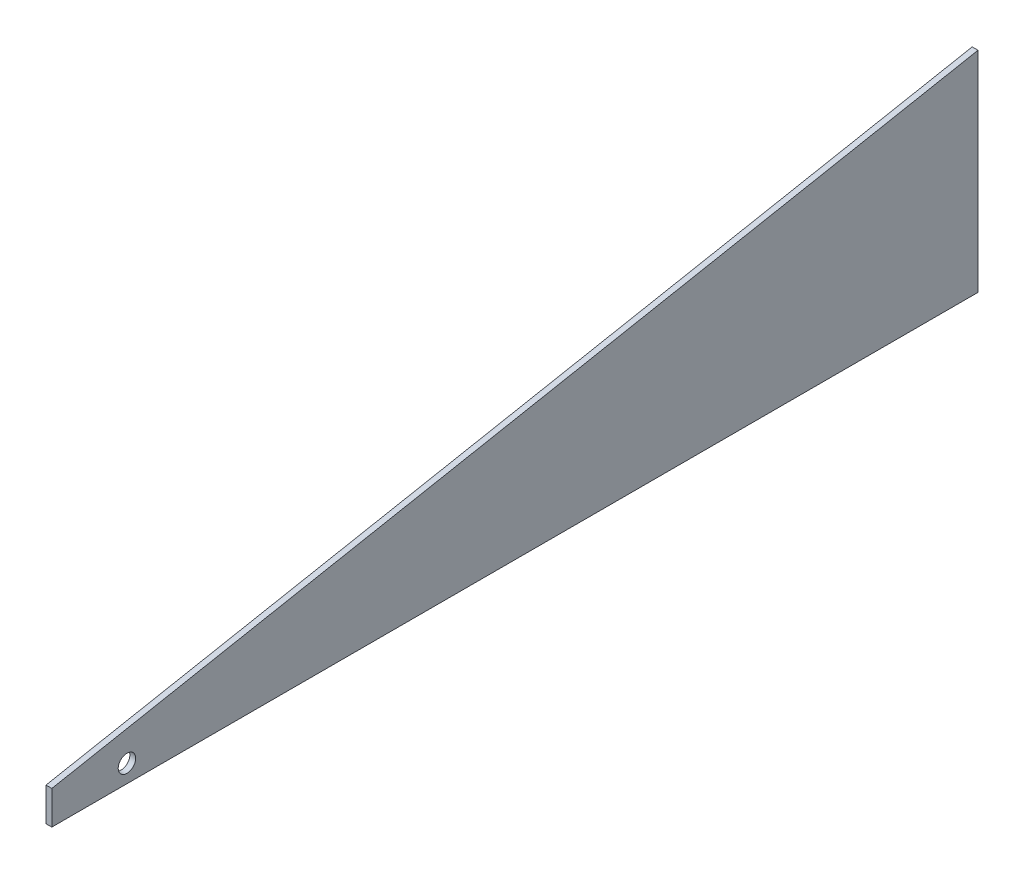
from build123d import *

# Parameters (mm, degrees)
RESSALTO_EXTRUS_O1_DEPTH                       = 2
BROCA_DE_ROSQUEAR_DE_CANO_PARA_TARRAXA_D_D     = 6
BROCA_DE_ROSQUEAR_DE_CANO_PARA_TARRAXA_D_DEPTH = 4
BROCA_DE_ROSQUEAR_DE_CANO_PARA_TARRAXA_D_TIP   = 1.802581857


with BuildPart() as part:
    # Esboço1 → Ressalto-extrusão1 (new body)
    with BuildSketch(Plane(origin=(0, 0, 0), x_dir=(0, 0, -1), z_dir=(1, 0, 0))):
        Polygon((-131, -26), (-131, -37.5), (187, -37.5), (187, 34.5), align=None)
    extrude(amount=RESSALTO_EXTRUS_O1_DEPTH)

    # Broca de rosquear de cano para tarraxa de 1/810
    with Locations(Plane(origin=(2, 0, 0), x_dir=(0, 0, -1), z_dir=(1, 0, 0))):
        with Locations((-105.202549234, -31.420254628)):
            Hole(BROCA_DE_ROSQUEAR_DE_CANO_PARA_TARRAXA_D_D / 2, depth=BROCA_DE_ROSQUEAR_DE_CANO_PARA_TARRAXA_D_DEPTH)
            with Locations((0, 0, -(BROCA_DE_ROSQUEAR_DE_CANO_PARA_TARRAXA_D_DEPTH + BROCA_DE_ROSQUEAR_DE_CANO_PARA_TARRAXA_D_TIP / 2))):  # 118° drill point
                Cone(0, BROCA_DE_ROSQUEAR_DE_CANO_PARA_TARRAXA_D_D / 2, BROCA_DE_ROSQUEAR_DE_CANO_PARA_TARRAXA_D_TIP, mode=Mode.SUBTRACT)


solid = part.part
